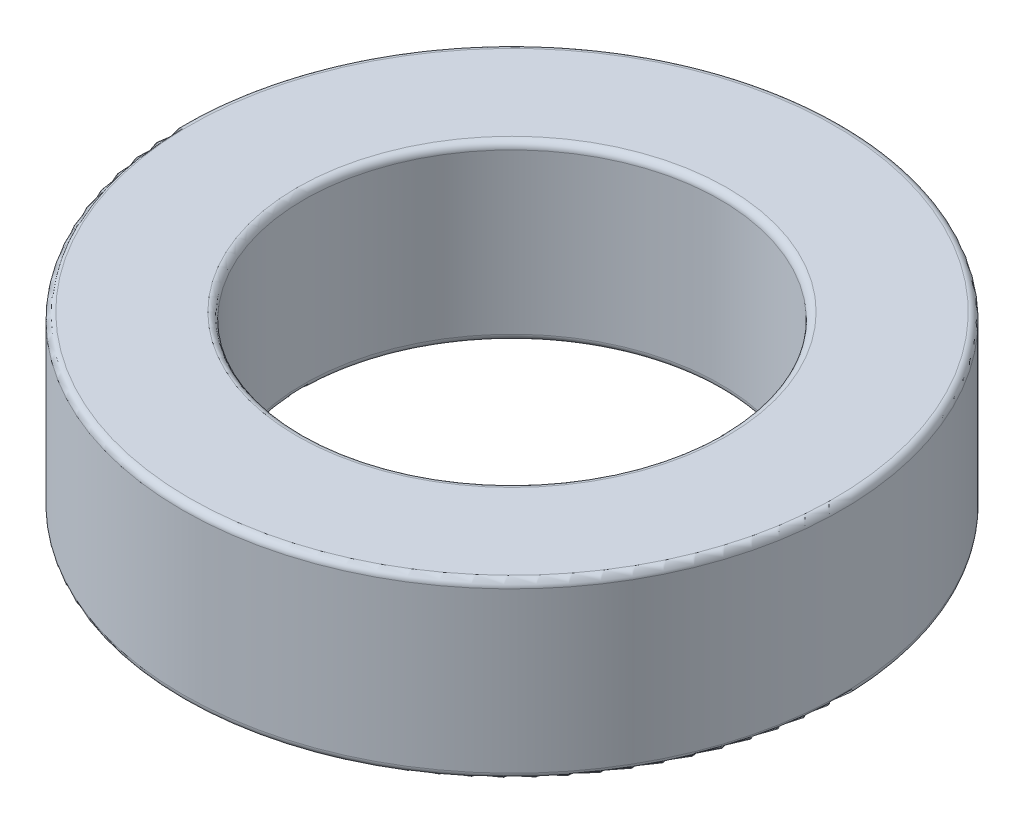
from build123d import *

# Parameters (mm, degrees)
SKETCH1_R           = 9.5
SKETCH1_R_2         = 6
BOSS_EXTRUDE1_DEPTH = 5
FILLET1_R           = 0.2


with BuildPart() as part:
    # Sketch1 → Boss-Extrude1 (new body)
    with BuildSketch(Plane(origin=(0, 0, 0), x_dir=(1, 0, 0), z_dir=(0, 1, 0))):
        Circle(SKETCH1_R)
        Circle(SKETCH1_R_2, mode=Mode.SUBTRACT)
    extrude(amount=BOSS_EXTRUDE1_DEPTH)

    # Fillet1
    fillet1_edges = [part.edges().sort_by_distance(p)[0] for p in [
        (-9.5, 0, 0),
        (-9.5, 5, 0),
        (-6, 0, 0),
        (-6, 5, 0),
    ]]
    fillet(fillet1_edges, radius=FILLET1_R)


solid = part.part
